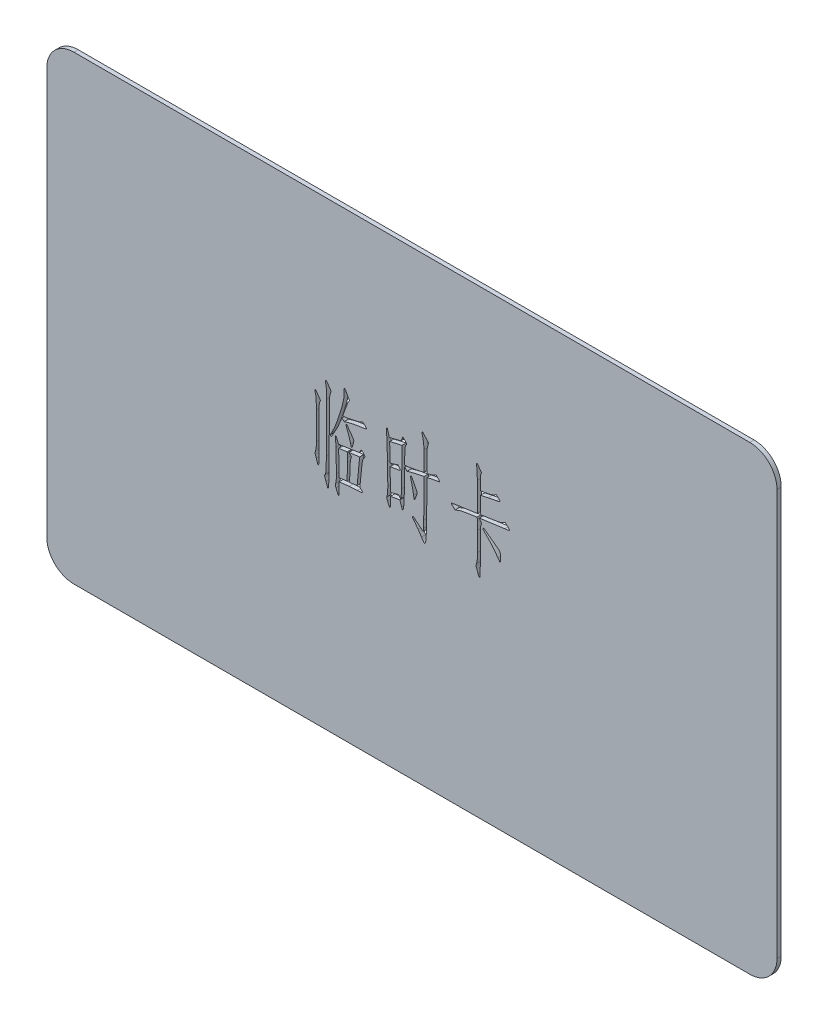
from build123d import *

# Parameters (mm, degrees)
SKETCH_1_W          = 85.6
SKETCH_1_H          = 54
EXTRUDE_1_DEPTH     = 0.5
CUT_EXTRUDE_1_DEPTH = 0.5
FILLET_1_R          = 3.18
FILLET_2_R          = 3.18


with BuildPart() as part:
    # 草图1 → 凸台-拉伸1 (new body)
    with BuildSketch(Plane.XY):
        with Locations((42.8, 27)):
            Rectangle(SKETCH_1_W, SKETCH_1_H)
    extrude(amount=EXTRUDE_1_DEPTH)

    # 草图2 → 切除-拉伸1 (cut)
    with BuildSketch(Plane.XY.offset(0.5)):
        with BuildLine():
            Line((31.503132567, 33.936108237), (31.963392528, 33.279811625))
            add(Edge.make_bspline(
                [(31.963392528, 33.279811625), (31.981078328, 33.252350472), (32.011774506, 33.204687803), (32.055946172, 33.146976419), (32.074726072, 33.107934182), (32.092294821, 33.086168682), (32.084178829, 33.06695685), (32.071883807, 33.043464326), (32.052003741, 33.00662995), (32.013038542, 32.942056313), (31.970597751, 32.840645055), (31.951912225, 32.723613117), (31.94453903, 32.615534282), (31.935113376, 32.516197794), (31.927976847, 32.399509095), (31.910476462, 32.228395715), (31.898688557, 32.017335525), (31.90328572, 31.85073494), (31.905433866, 31.772886417)],
                knots=[0, 0, 0, 0, 9.834e-05, 0.000170683, 0.000214244, 0.000233303, 0.000245713, 0.000272395, 0.000315114, 0.000370088, 0.000499249, 0.000641351, 0.000723459, 0.000824395, 0.000940625, 0.001074124, 0.001340401, 0.001573965, 0.001573965, 0.001573965, 0.001573965], degree=3))
            Line((31.905433866, 31.772886417), (31.939527197, 27.422577447))
            Line((31.939527197, 27.422577447), (31.917366532, 26.916291489))
            add(Edge.make_bspline(
                [(31.917366532, 26.916291489), (31.914325094, 26.859942278), (31.908848705, 26.758480344), (31.896859864, 26.625365958), (31.8792326, 26.524721034), (31.86451619, 26.46386102), (31.836727153, 26.419797843), (31.79488277, 26.438700918), (31.770649788, 26.489700962), (31.753841724, 26.533217007), (31.743490547, 26.560016185)],
                knots=[0, 0, 0, 0, 0.000169072, 0.000304429, 0.000403079, 0.000469386, 0.000504363, 0.000531316, 0.000585222, 0.000671641, 0.000671641, 0.000671641, 0.000671641], degree=3))
            Line((31.743490547, 26.560016185), (31.595184559, 26.986182816))
            Line((31.595184559, 26.986182816), (31.491199901, 27.30836479))
            add(Edge.make_bspline(
                [(31.491199901, 27.30836479), (31.482392373, 27.328702458), (31.466657222, 27.365036863), (31.449792822, 27.413590118), (31.440274613, 27.448227468), (31.436003442, 27.484364348), (31.4610294, 27.536229863), (31.487251409, 27.621857061), (31.524376906, 27.73687249), (31.548415746, 27.873976767), (31.570952938, 28.01802919), (31.591655278, 28.144491099), (31.605284742, 28.259926994), (31.613990233, 28.374192809), (31.615846507, 28.516403958), (31.616815679, 28.62039338), (31.617345224, 28.677212009)],
                knots=[0, 0, 0, 0, 6.6482e-05, 0.000118774, 0.000153916, 0.000174443, 0.000226205, 0.000320008, 0.000446222, 0.000586968, 0.000737182, 0.000883764, 0.000971301, 0.001085831, 0.00122736, 0.001397835, 0.001397835, 0.001397835, 0.001397835], degree=3))
            Line((31.617345224, 28.677212009), (31.605412558, 31.887099075))
            add(Edge.make_bspline(
                [(31.605412558, 31.887099075), (31.603670688, 31.999037051), (31.600460981, 32.205302862), (31.596584961, 32.487759312), (31.588389678, 32.716684957), (31.584455721, 32.8980351), (31.577099005, 33.042929643), (31.569457773, 33.16300598), (31.557717059, 33.262517759), (31.543385343, 33.34857591), (31.521558457, 33.433869833), (31.49706767, 33.533741522), (31.462131186, 33.653452639), (31.435636183, 33.739542871), (31.421308573, 33.786097583)],
                knots=[0, 0, 0, 0, 0.000335858, 0.000618879, 0.000847406, 0.001023061, 0.00116301, 0.001282641, 0.001383922, 0.001463513, 0.001544139, 0.001647914, 0.001772015, 0.00191815, 0.00191815, 0.00191815, 0.00191815], degree=3))
            Line((31.421308573, 33.786097583), (31.503132567, 33.936108237))
        make_face()
        with BuildLine():
            Line((32.745834463, 35.500992107), (33.354400412, 34.636726179))
            add(Edge.make_bspline(
                [(33.354400412, 34.636726179), (33.320672072, 34.561332709), (33.257467607, 34.420050811), (33.194806462, 34.203212096), (33.163776432, 33.985802492), (33.146503569, 33.763091258), (33.139026653, 33.540676962), (33.137114222, 33.395163504), (33.136203097, 33.325837621)],
                knots=[0, 0, 0, 0, 0.00024757, 0.000463929, 0.000674405, 0.000905297, 0.001133882, 0.001341879, 0.001341879, 0.001341879, 0.001341879], degree=3))
            Line((33.136203097, 33.325837621), (33.090177101, 26.34181887))
            add(Edge.make_bspline(
                [(33.090177101, 26.34181887), (33.088269852, 26.317395295), (33.083308271, 26.253859017), (33.081740441, 26.136108334), (33.076801935, 25.974212693), (33.07988348, 25.701374999), (33.071800899, 25.33510591), (33.048246638, 25.005344707), (33.028972086, 24.801144628), (33.016908771, 24.725631704), (33.000213651, 24.675059461), (32.989233396, 24.63887802), (32.959259049, 24.627032513), (32.935913585, 24.655047628), (32.916444475, 24.695699297), (32.902451528, 24.731691931), (32.894140451, 24.753069669)],
                knots=[0, 0, 0, 0, 7.3479e-05, 0.00019115, 0.000353129, 0.000559394, 0.001009542, 0.001452116, 0.001549819, 0.001626054, 0.001679445, 0.001712235, 0.001733798, 0.001760426, 0.001806954, 0.001875013, 0.001875013, 0.001875013, 0.001875013], degree=3))
            Line((32.894140451, 24.753069669), (32.733901797, 25.201396965))
            Line((32.733901797, 25.201396965), (32.595823809, 25.615630931))
            add(Edge.make_bspline(
                [(32.595823809, 25.615630931), (32.585154766, 25.639937077), (32.569246104, 25.676180095), (32.549963702, 25.723224535), (32.5638671, 25.751843619), (32.581424107, 25.779476348), (32.60422155, 25.821027168), (32.638119871, 25.870898794), (32.673451554, 25.935429917), (32.696956735, 26.017358663), (32.714063252, 26.11333982), (32.723227674, 26.22633739), (32.728805975, 26.361159178), (32.73829394, 26.521330643), (32.746024559, 26.709477251), (32.759646318, 26.991823607), (32.777731898, 27.347940166), (32.779215815, 27.632225632), (32.779927793, 27.768624751)],
                knots=[0, 0, 0, 0, 8.17e-05, 0.000121823, 0.000140183, 0.000173804, 0.000221168, 0.000281701, 0.000354903, 0.000440629, 0.000535923, 0.000647197, 0.000780336, 0.000940801, 0.001128508, 0.001345242, 0.001788852, 0.002198004, 0.002198004, 0.002198004, 0.002198004], degree=3))
            Line((32.779927793, 27.768624751), (32.814021124, 33.590060933))
            add(Edge.make_bspline(
                [(32.814021124, 33.590060933), (32.813649768, 33.702587882), (32.812871164, 33.938517304), (32.799198515, 34.235005466), (32.790131266, 34.472680082), (32.777053401, 34.632791797), (32.766030183, 34.771594961), (32.747579479, 34.929914533), (32.717363543, 35.117779981), (32.682045973, 35.264250953), (32.66401047, 35.339048787)],
                knots=[0, 0, 0, 0, 0.000337541, 0.000707705, 0.000890303, 0.001050986, 0.001189578, 0.001307988, 0.001529103, 0.001759857, 0.001759857, 0.001759857, 0.001759857], degree=3))
            Line((32.66401047, 35.339048787), (32.745834463, 35.500992107))
        make_face()
        with BuildLine():
            Line((33.228255089, 30.172204551), (33.366333078, 30.426199863))
            add(Edge.make_bspline(
                [(33.366333078, 30.426199863), (33.418069659, 30.523629017), (33.518437471, 30.7126394), (33.65458119, 30.992474107), (33.775243936, 31.258594148), (33.880324394, 31.523573771), (33.986606708, 31.804110585), (34.098028155, 32.122578456), (34.224829131, 32.486208303), (34.35543785, 32.883255605), (34.485020634, 33.280547275), (34.594351328, 33.651820528), (34.682614729, 33.979405597), (34.745500345, 34.265979822), (34.791790456, 34.510698941), (34.824780836, 34.714388576), (34.851549905, 34.876495379), (34.861068284, 35.002571057), (34.866613625, 35.100929114), (34.869080285, 35.181112289), (34.873991702, 35.247516292), (34.873483279, 35.287334555), (34.873258286, 35.304955456)],
                knots=[0, 0, 0, 0, 0.000330916, 0.00064197, 0.000933443, 0.001207258, 0.001496956, 0.001833394, 0.002219387, 0.002652255, 0.003087305, 0.003472971, 0.003813264, 0.004104847, 0.004352921, 0.004560303, 0.004723995, 0.004845458, 0.004939354, 0.005019546, 0.005086115, 0.00513896, 0.00513896, 0.00513896, 0.00513896], degree=3))
            Line((34.873258286, 35.304955456), (34.863030287, 35.673163426))
            Line((34.863030287, 35.673163426), (34.955082279, 35.731122088))
            Line((34.955082279, 35.731122088), (35.483528902, 34.774804167))
            add(Edge.make_bspline(
                [(35.483528902, 34.774804167), (35.458650142, 34.745065837), (35.410922237, 34.688015232), (35.354217851, 34.606932921), (35.31068183, 34.51697812), (35.265883924, 34.40556943), (35.206676499, 34.249098129), (35.163430548, 34.12937309), (35.139186264, 34.06225356)],
                knots=[0, 0, 0, 0, 0.000116343, 0.000223194, 0.000295617, 0.0004156, 0.000583395, 0.000797485, 0.000797485, 0.000797485, 0.000797485], degree=3))
            Line((35.139186264, 34.06225356), (34.689154301, 32.819551664))
            add(Edge.make_bspline(
                [(34.689154301, 32.819551664), (34.722129662, 32.820982648), (34.792733145, 32.824046526), (34.904694142, 32.834912963), (35.030468172, 32.849848403), (35.168623565, 32.873676914), (35.321471003, 32.895851437), (35.486031964, 32.927510806), (35.664422418, 32.963477215), (35.85014408, 33.003142971), (36.033054394, 33.043179881), (36.200822189, 33.080063428), (36.348462261, 33.114619506), (36.47528983, 33.144812588), (36.58170967, 33.171646695), (36.666932987, 33.196901792), (36.733458451, 33.213206634), (36.816120956, 33.246247555), (36.921870652, 33.297811055), (37.005867502, 33.354886821), (37.048412771, 33.383796283)],
                knots=[0, 0, 0, 0, 9.9003e-05, 0.000211975, 0.000337358, 0.000478886, 0.000632467, 0.000800642, 0.000981506, 0.00117843, 0.001370354, 0.001543233, 0.001693747, 0.001825227, 0.001934379, 0.002022891, 0.002091966, 0.002139453, 0.002289638, 0.002443785, 0.002443785, 0.002443785, 0.002443785], degree=3))
            Line((37.048412771, 33.383796283), (37.428553406, 33.037748979))
            add(Edge.make_bspline(
                [(37.428553406, 33.037748979), (37.441140452, 33.020730815), (37.463294861, 32.990777213), (37.482094266, 32.949255413), (37.477741313, 32.91704327), (37.456388525, 32.897733325), (37.424337765, 32.880236014), (37.397523302, 32.870835092), (37.38252741, 32.86557766)],
                knots=[0, 0, 0, 0, 6.3828e-05, 0.000112344, 0.000131403, 0.000156744, 0.00019417, 0.000241656, 0.000241656, 0.000241656, 0.000241656], degree=3))
            add(Edge.make_bspline(
                [(37.38252741, 32.86557766), (37.359937537, 32.857699745), (37.308800753, 32.839866478), (37.218809872, 32.822493465), (37.108863484, 32.808181077), (37.003087268, 32.796619088), (36.903833393, 32.789440929), (36.814361518, 32.77589199), (36.711174825, 32.763542655), (36.595484994, 32.743695159), (36.466425216, 32.721992806), (36.324425794, 32.696062105), (36.169843919, 32.66721652), (35.951174456, 32.625175218), (35.683045141, 32.567334613), (35.379096252, 32.493137388), (35.104227291, 32.413849681), (34.932683034, 32.353771291), (34.851097621, 32.325198371)],
                knots=[0, 0, 0, 0, 7.1697e-05, 0.000162302, 0.000274162, 0.000404433, 0.000481445, 0.000572577, 0.000675762, 0.000793186, 0.000924623, 0.001068402, 0.00122621, 0.001396378, 0.001736411, 0.002048975, 0.002334881, 0.002594176, 0.002594176, 0.002594176, 0.002594176], degree=3))
            Line((34.851097621, 32.325198371), (34.609034974, 32.577489017))
            add(Edge.make_bspline(
                [(34.609034974, 32.577489017), (34.565272961, 32.471235817), (34.483092538, 32.271703572), (34.3680839, 31.992080189), (34.26540559, 31.753012561), (34.17390812, 31.545064008), (34.081650994, 31.351045637), (33.983796347, 31.15187403), (33.87002096, 30.93993801), (33.76821846, 30.75763833), (33.686225019, 30.61282825), (33.628795136, 30.515201262), (33.580332095, 30.427944358), (33.535962392, 30.354186014), (33.499396447, 30.291491459), (33.470342442, 30.240416388), (33.443317483, 30.203450671), (33.429869123, 30.181364329), (33.42429174, 30.172204551)],
                knots=[0, 0, 0, 0, 0.000344739, 0.000647383, 0.00090703, 0.001125288, 0.001328887, 0.001551494, 0.00179095, 0.002050401, 0.002177898, 0.002290173, 0.002390184, 0.002477305, 0.002548351, 0.00260799, 0.00265338, 0.002685544, 0.002685544, 0.002685544, 0.002685544], degree=3))
            Line((33.42429174, 30.172204551), (33.332239747, 30.046059228))
            Line((33.332239747, 30.046059228), (33.228255089, 30.172204551))
        make_face()
        with BuildLine():
            Line((34.274920336, 25.927584905), (34.274920336, 24.995132316))
            add(Edge.make_bspline(
                [(34.274920336, 24.995132316), (34.273660543, 24.917316917), (34.271355245, 24.774922191), (34.257798346, 24.619932698), (34.238969178, 24.537084481), (34.231039751, 24.512359982), (34.213018906, 24.498775214), (34.193018932, 24.510540134), (34.174179782, 24.530884451), (34.152518671, 24.56635613), (34.127795546, 24.614712324), (34.111603236, 24.652362571), (34.102749017, 24.672950342)],
                knots=[0, 0, 0, 0, 0.000233639, 0.000427537, 0.000464335, 0.000488742, 0.000504824, 0.000523184, 0.000549702, 0.000590365, 0.000646022, 0.000713178, 0.000713178, 0.000713178, 0.000713178], degree=3))
            Line((34.102749017, 24.672950342), (33.906712366, 25.121277638))
            add(Edge.make_bspline(
                [(33.906712366, 25.121277638), (33.893665389, 25.152523666), (33.870499006, 25.208004522), (33.839782549, 25.280985109), (33.823924508, 25.334655272), (33.817783089, 25.374308445), (33.82553839, 25.408747259), (33.838590121, 25.449482287), (33.852397803, 25.503576459), (33.87492718, 25.568355719), (33.894974817, 25.648034878), (33.913925451, 25.742307561), (33.926546108, 25.852366879), (33.937034304, 25.976862926), (33.942182035, 26.115680264), (33.951069695, 26.267852238), (33.950627794, 26.432747585), (33.952018695, 26.546951695), (33.952738362, 26.606042181)],
                knots=[0, 0, 0, 0, 0.000101624, 0.000180446, 0.000237111, 0.000269679, 0.000299106, 0.000341723, 0.000398389, 0.000466319, 0.000547358, 0.000644643, 0.000754591, 0.000879451, 0.0010194, 0.001171269, 0.00133663, 0.001513924, 0.001513924, 0.001513924, 0.001513924], degree=3))
            Line((33.952738362, 26.606042181), (33.906712366, 29.229523963))
            Line((33.906712366, 29.229523963), (33.86068637, 29.954007236))
            Line((33.86068637, 29.954007236), (33.814660374, 30.334147871))
            Line((33.814660374, 30.334147871), (33.918645032, 30.402334532))
            Line((33.918645032, 30.402334532), (34.194801009, 29.711944589))
            Line((34.194801009, 29.711944589), (36.634178806, 30.080152559))
            Line((36.634178806, 30.080152559), (36.81828279, 30.402334532))
            add(Edge.make_bspline(
                [(36.81828279, 30.402334532), (36.825752315, 30.414961605), (36.838930453, 30.437238968), (36.872173215, 30.460047182), (36.911735946, 30.451121317), (36.932649467, 30.435178803), (36.944428113, 30.426199863)],
                knots=[0, 0, 0, 0, 4.3992e-05, 7.7614e-05, 0.000112088, 0.000156541, 0.000156541, 0.000156541, 0.000156541], degree=3))
            Line((36.944428113, 30.426199863), (37.22058409, 30.126178555))
            add(Edge.make_bspline(
                [(37.22058409, 30.126178555), (37.242499546, 30.100687071), (37.27810463, 30.05927217), (37.301437443, 29.992987504), (37.285687916, 29.946228108), (37.263251712, 29.902953688), (37.226295076, 29.848569427), (37.159772774, 29.759058178), (37.074453383, 29.62139179), (37.014668469, 29.419281887), (36.971784856, 29.197865096), (36.95367131, 29.043878681), (36.944428113, 28.965300651)],
                knots=[0, 0, 0, 0, 0.000101266, 0.000164523, 0.000196369, 0.000245922, 0.000311168, 0.00039301, 0.000580995, 0.000792848, 0.001020515, 0.001257752, 0.001257752, 0.001257752, 0.001257752], degree=3))
            Line((36.944428113, 28.965300651), (36.704070133, 26.594109516))
            Line((36.704070133, 26.594109516), (36.944428113, 26.34181887))
            add(Edge.make_bspline(
                [(36.944428113, 26.34181887), (36.960925741, 26.322045365), (36.989024421, 26.288367226), (36.999887541, 26.228981663), (36.985190074, 26.183163726), (36.958230065, 26.15736961), (36.927657323, 26.149326087), (36.895534487, 26.145485179), (36.849779268, 26.137450403), (36.788739916, 26.1335588), (36.713205639, 26.128125766), (36.622766223, 26.123819957), (36.518351729, 26.115733336), (36.44384097, 26.113096878), (36.404048825, 26.111688889)],
                knots=[0, 0, 0, 0, 7.6121e-05, 0.000129648, 0.000172773, 0.000216234, 0.000234031, 0.000266821, 0.000313349, 0.000373231, 0.000450112, 0.000540604, 0.000644812, 0.000764248, 0.000764248, 0.000764248, 0.000764248], degree=3))
            Line((36.404048825, 26.111688889), (35.437502905, 26.053730227))
            Line((35.437502905, 26.053730227), (34.274920336, 25.927584905))
        make_face()
        with BuildLine():
            Line((34.264692336, 26.34181887), (35.207372925, 26.456031527))
            Line((35.207372925, 26.456031527), (35.253398921, 28.412988697))
            add(Edge.make_bspline(
                [(35.253398921, 28.412988697), (35.253398921, 28.494244468), (35.253398921, 28.6436869), (35.253398921, 28.793129332), (35.253398921, 28.861315993)],
                knots=[0, 0, 0, 0, 0.000243767, 0.000448327, 0.000448327, 0.000448327, 0.000448327], degree=3))
            Line((35.253398921, 28.861315993), (35.241466255, 29.10337864))
            add(Edge.make_bspline(
                [(35.241466255, 29.10337864), (35.239277084, 29.132337259), (35.235373342, 29.183976412), (35.23631281, 29.251785875), (35.230684675, 29.299354091), (35.23109081, 29.324411562), (35.231238256, 29.333508621)],
                knots=[0, 0, 0, 0, 8.7088e-05, 0.000155296, 0.000203149, 0.000230423, 0.000230423, 0.000230423, 0.000230423], degree=3))
            Line((35.231238256, 29.333508621), (35.21930559, 29.447721278))
            Line((35.21930559, 29.447721278), (34.21866634, 29.297710624))
            Line((34.21866634, 29.297710624), (34.264692336, 26.34181887))
        make_face(mode=Mode.SUBTRACT)
        with BuildLine():
            add(Edge.make_bspline(
                [(35.495461567, 26.490124858), (35.517631368, 26.491113179), (35.566580017, 26.493295291), (35.646155873, 26.500383723), (35.738103156, 26.51105425), (35.842641141, 26.523109316), (35.95984562, 26.53610593), (36.089230437, 26.553948987), (36.231438702, 26.572140847), (36.330201809, 26.586562261), (36.38188816, 26.594109516)],
                knots=[0, 0, 0, 0, 6.6569e-05, 0.000146978, 0.000239597, 0.000344264, 0.000462674, 0.000593345, 0.00073607, 0.000892769, 0.000892769, 0.000892769, 0.000892769], degree=3))
            Line((36.38188816, 26.594109516), (36.680204802, 29.655690594))
            Line((36.680204802, 29.655690594), (35.415342241, 29.481814608))
            Line((35.415342241, 29.481814608), (35.737524214, 29.183497967))
            add(Edge.make_bspline(
                [(35.737524214, 29.183497967), (35.718472725, 29.141598086), (35.678065616, 29.052730855), (35.629086252, 28.930308048), (35.59747819, 28.800097704), (35.584148195, 28.655809977), (35.569655317, 28.468355924), (35.565785669, 28.328368748), (35.563648228, 28.251045378)],
                knots=[0, 0, 0, 0, 0.00013812, 0.000292945, 0.000394655, 0.000538858, 0.000726867, 0.000958858, 0.000958858, 0.000958858, 0.000958858], degree=3))
            Line((35.563648228, 28.251045378), (35.495461567, 26.490124858))
        make_face(mode=Mode.SUBTRACT)
        with BuildLine():
            Line((35.149414263, 32.197348382), (35.633539556, 31.576849767))
            Line((35.633539556, 31.576849767), (35.885830201, 31.184776466))
            add(Edge.make_bspline(
                [(35.885830201, 31.184776466), (35.899839946, 31.161680898), (35.925718905, 31.119018505), (35.956470755, 31.056689769), (35.979736685, 31.003743045), (35.994359556, 30.940738081), (35.99269031, 30.858884909), (35.976529545, 30.795257898), (35.967654194, 30.760314502)],
                knots=[0, 0, 0, 0, 8.0985e-05, 0.000149597, 0.000208476, 0.000253962, 0.000342604, 0.000450592, 0.000450592, 0.000450592, 0.000450592], degree=3))
            Line((35.967654194, 30.760314502), (35.81764354, 30.254028544))
            add(Edge.make_bspline(
                [(35.81764354, 30.254028544), (35.813836307, 30.23672471), (35.807287147, 30.206958845), (35.790017637, 30.170743283), (35.769529369, 30.146620803), (35.733075779, 30.138525749), (35.690199782, 30.176667178), (35.683527946, 30.217716653), (35.679565552, 30.242095878)],
                knots=[0, 0, 0, 0, 5.2927e-05, 9.1045e-05, 0.000119974, 0.000144381, 0.000194517, 0.000267837, 0.000267837, 0.000267837, 0.000267837], degree=3))
            Line((35.679565552, 30.242095878), (35.62160689, 30.472225859))
            add(Edge.make_bspline(
                [(35.62160689, 30.472225859), (35.586786087, 30.60092787), (35.515354405, 30.864948227), (35.386990688, 31.264032448), (35.238061549, 31.676619243), (35.126447863, 31.953360305), (35.069294936, 32.095068391)],
                knots=[0, 0, 0, 0, 0.000399943, 0.000820447, 0.001257221, 0.001715586, 0.001715586, 0.001715586, 0.001715586], degree=3))
            Line((35.069294936, 32.095068391), (35.149414263, 32.197348382))
        make_face()
        with BuildLine():
            Line((39.920775865, 34.188398883), (40.162838512, 33.371863618))
            Line((40.162838512, 33.371863618), (41.553846396, 33.728138921))
            Line((41.553846396, 33.728138921), (41.691924384, 34.096346891))
            add(Edge.make_bspline(
                [(41.691924384, 34.096346891), (41.697942424, 34.119711547), (41.707079559, 34.15518589), (41.743906869, 34.203904165), (41.803302659, 34.175456185), (41.83386281, 34.148249749), (41.853867704, 34.130440221)],
                knots=[0, 0, 0, 0, 7.4422e-05, 0.000112994, 0.00015725, 0.000241126, 0.000241126, 0.000241126, 0.000241126], degree=3))
            Line((41.853867704, 34.130440221), (42.130023681, 33.820190914))
            add(Edge.make_bspline(
                [(42.130023681, 33.820190914), (42.148114142, 33.798323742), (42.177389077, 33.762937135), (42.201249103, 33.695969698), (42.162444543, 33.626640387), (42.105560241, 33.541137414), (42.038649302, 33.412247175), (42.003795661, 33.272984485), (41.984410326, 33.134787454), (41.975612036, 32.999785217), (41.968274132, 32.837816275), (41.968148194, 32.72069356), (41.968080361, 32.657608344)],
                knots=[0, 0, 0, 0, 8.5608e-05, 0.000138535, 0.000198996, 0.000309221, 0.000454068, 0.000628993, 0.000737478, 0.000872534, 0.001034621, 0.001223847, 0.001223847, 0.001223847, 0.001223847], degree=3))
            Line((41.968080361, 32.657608344), (41.957852362, 31.460932443))
            Line((41.957852362, 31.460932443), (42.234008339, 31.484797775))
            Line((42.234008339, 31.484797775), (42.728361631, 31.552984436))
            Line((42.728361631, 31.552984436), (43.384658243, 31.680834425))
            Line((43.384658243, 31.680834425), (44.223354173, 31.853005744))
            Line((44.223354173, 31.853005744), (44.223354173, 34.176466217))
            add(Edge.make_bspline(
                [(44.223354173, 34.176466217), (44.223115446, 34.211139347), (44.222606265, 34.285093473), (44.214667324, 34.402124923), (44.205053151, 34.532371684), (44.184180972, 34.717058282), (44.156999232, 34.939686692), (44.122035426, 35.154838486), (44.090155673, 35.323825128), (44.055349101, 35.465279203), (44.010329016, 35.625774633), (43.97688889, 35.739118615), (43.959130862, 35.799308749)],
                knots=[0, 0, 0, 0, 0.000103999, 0.000221818, 0.000351776, 0.000495787, 0.000779326, 0.001024544, 0.001149578, 0.001295115, 0.001461371, 0.001649634, 0.001649634, 0.001649634, 0.001649634], degree=3))
            Line((43.959130862, 35.799308749), (44.051182854, 35.891360741))
            Line((44.051182854, 35.891360741), (44.765438128, 35.120851472))
            add(Edge.make_bspline(
                [(44.765438128, 35.120851472), (44.742596976, 35.052307347), (44.699097142, 34.921768484), (44.647329772, 34.731264139), (44.610645572, 34.555981871), (44.583671321, 34.338022049), (44.572585089, 34.063517356), (44.570491002, 33.842915141), (44.569401478, 33.728138921)],
                knots=[0, 0, 0, 0, 0.000216714, 0.000412721, 0.000591914, 0.000753453, 0.001070979, 0.001415359, 0.001415359, 0.001415359, 0.001415359], degree=3))
            Line((44.569401478, 33.728138921), (44.557468812, 31.910964406))
            Line((44.557468812, 31.910964406), (44.959770112, 32.013244397))
            add(Edge.make_bspline(
                [(44.959770112, 32.013244397), (45.023299271, 32.030039118), (45.147284114, 32.062816047), (45.322141723, 32.134428405), (45.484635522, 32.217966698), (45.580580207, 32.289730311), (45.627999389, 32.325198371)],
                knots=[0, 0, 0, 0, 0.000196924, 0.000384321, 0.000565818, 0.000743177, 0.000743177, 0.000743177, 0.000743177], degree=3))
            Line((45.627999389, 32.325198371), (45.996207359, 31.945057736))
            add(Edge.make_bspline(
                [(45.996207359, 31.945057736), (46.00854117, 31.927465973), (46.030625716, 31.895966699), (46.047454555, 31.846924521), (46.031565737, 31.798011554), (46.001164352, 31.796105822), (45.984274693, 31.795047082)],
                knots=[0, 0, 0, 0, 6.4327e-05, 0.000115182, 0.000151902, 0.000197801, 0.000197801, 0.000197801, 0.000197801], degree=3))
            Line((45.984274693, 31.795047082), (45.834264039, 31.760953752))
            add(Edge.make_bspline(
                [(45.834264039, 31.760953752), (45.82748062, 31.758549422), (45.804290299, 31.750329793), (45.752934119, 31.742737593), (45.672128937, 31.727526609), (45.583614762, 31.717023901), (45.493116786, 31.70436697), (45.406158745, 31.68885089), (45.304330509, 31.667229166), (45.185471241, 31.646705295), (45.051390857, 31.615966282), (44.900365624, 31.585084036), (44.734289443, 31.546266684), (44.618294003, 31.52048023), (44.557468812, 31.50695844)],
                knots=[0, 0, 0, 0, 2.1563e-05, 7.3715e-05, 0.000154987, 0.000268536, 0.000340859, 0.00042914, 0.000533446, 0.000653137, 0.000790889, 0.000946023, 0.001115575, 0.001302506, 0.001302506, 0.001302506, 0.001302506], degree=3))
            Line((44.557468812, 31.50695844), (44.535308147, 26.54808352))
            add(Edge.make_bspline(
                [(44.535308147, 26.54808352), (44.534019371, 26.543560467), (44.529913091, 26.529149178), (44.530995384, 26.498482534), (44.525619502, 26.452162451), (44.52332732, 26.388967277), (44.519084485, 26.309480611), (44.518768056, 26.213370858), (44.51437183, 26.101474362), (44.510457749, 25.933817484), (44.504591648, 25.723437238), (44.49017462, 25.483683754), (44.474883456, 25.265671733), (44.450237164, 25.074283995), (44.427674505, 24.914887782), (44.393115079, 24.797696057), (44.361782256, 24.720701111), (44.313655159, 24.683977023), (44.275004351, 24.697415643), (44.243165727, 24.719289775), (44.203622272, 24.753848038), (44.159713325, 24.804079036), (44.111241791, 24.869996491), (44.05237341, 24.947530824), (43.990274255, 25.041500316), (43.94762437, 25.109258888), (43.925037531, 25.14514297)],
                knots=[0, 0, 0, 0, 1.4057e-05, 4.4788e-05, 9.094e-05, 0.000154105, 0.000234297, 0.000329774, 0.000442333, 0.000570229, 0.000832886, 0.00107363, 0.001290793, 0.001488277, 0.001652501, 0.001773328, 0.001852645, 0.001903814, 0.001930277, 0.001968585, 0.002020542, 0.002086937, 0.002168423, 0.002265932, 0.00237893, 0.002506142, 0.002506142, 0.002506142, 0.002506142], degree=3))
            Line((43.925037531, 25.14514297), (43.522736232, 25.753708919))
            Line((43.522736232, 25.753708919), (43.038610939, 26.398072865))
            Line((43.038610939, 26.398072865), (42.86643962, 26.640135512))
            Line((42.86643962, 26.640135512), (42.924398281, 26.7782135))
            Line((42.924398281, 26.7782135), (43.118730265, 26.628202846))
            Line((43.118730265, 26.628202846), (43.752866212, 26.099756224))
            add(Edge.make_bspline(
                [(43.752866212, 26.099756224), (43.802050768, 26.058323359), (43.887625674, 25.986235416), (43.999793075, 25.887057911), (44.070152198, 25.841888669), (44.123128972, 25.792842176), (44.155997515, 25.837687747), (44.155814711, 25.904760071), (44.169368504, 26.016160029), (44.167937642, 26.105452988), (44.167100178, 26.157714885)],
                knots=[0, 0, 0, 0, 0.000194698, 0.00033875, 0.000432507, 0.000476729, 0.000504479, 0.000570347, 0.000681477, 0.000838316, 0.000838316, 0.000838316, 0.000838316], degree=3))
            Line((44.167100178, 26.157714885), (44.189260843, 26.996410816))
            Line((44.189260843, 26.996410816), (44.223354173, 31.438771779))
            add(Edge.make_bspline(
                [(44.223354173, 31.438771779), (44.058362521, 31.41150994), (43.726122678, 31.356613412), (43.228795615, 31.252723714), (42.730418889, 31.126184724), (42.400177431, 31.027944032), (42.234008339, 30.978511817)],
                knots=[0, 0, 0, 0, 0.000501647, 0.001010155, 0.001523653, 0.002043714, 0.002043714, 0.002043714, 0.002043714], degree=3))
            Line((42.234008339, 30.978511817), (41.957852362, 31.254667794))
            Line((41.957852362, 31.254667794), (41.922054365, 28.769264001))
            add(Edge.make_bspline(
                [(41.922054365, 28.769264001), (41.918712581, 28.680050444), (41.911369318, 28.484011867), (41.900780629, 28.234619914), (41.896023519, 28.028226424), (41.887699355, 27.890834624), (41.88413692, 27.775902066), (41.878532097, 27.707243295), (41.876028369, 27.676572759)],
                knots=[0, 0, 0, 0, 0.000267828, 0.000588527, 0.000748848, 0.000887094, 0.001001421, 0.001093725, 0.001093725, 0.001093725, 0.001093725], degree=3))
            Line((41.876028369, 27.676572759), (41.853867704, 27.30836479))
            add(Edge.make_bspline(
                [(41.853867704, 27.30836479), (41.849659272, 27.274866307), (41.842032481, 27.214158202), (41.834824671, 27.132045956), (41.825684467, 27.069112685), (41.816892788, 27.004724089), (41.793532019, 26.921529676), (41.762961947, 26.847535241), (41.739308373, 26.79292727), (41.718158304, 26.780491926), (41.695495587, 26.78873292), (41.678951238, 26.814918206), (41.656130763, 26.851359082), (41.634700853, 26.905790897), (41.613983955, 26.975329554), (41.59821665, 27.02653206), (41.589644393, 27.054369477)],
                knots=[0, 0, 0, 0, 0.000101281, 0.000183547, 0.000247193, 0.000292036, 0.000378455, 0.000504761, 0.00053458, 0.000553639, 0.000571436, 0.000600466, 0.000644027, 0.00070133, 0.00077465, 0.000862005, 0.000862005, 0.000862005, 0.000862005], degree=3))
            Line((41.589644393, 27.054369477), (41.393607742, 27.652707427))
            Line((41.393607742, 27.652707427), (40.3009165, 27.468603443))
            Line((40.3009165, 27.468603443), (40.288983834, 26.698094174))
            add(Edge.make_bspline(
                [(40.288983834, 26.698094174), (40.287233118, 26.643435411), (40.284203695, 26.548854399), (40.274335242, 26.429207895), (40.269265723, 26.349127613), (40.25743703, 26.304697163), (40.23889728, 26.278850203), (40.224419361, 26.282512676), (40.219092507, 26.283860208)],
                knots=[0, 0, 0, 0, 0.00016379, 0.000283421, 0.000362297, 0.000400032, 0.00042655, 0.000441986, 0.000441986, 0.000441986, 0.000441986], degree=3))
            add(Edge.make_bspline(
                [(40.219092507, 26.283860208), (40.209570109, 26.285895774), (40.188392123, 26.29042291), (40.16271777, 26.31904178), (40.137185701, 26.358291844), (40.124124821, 26.391444551), (40.116812515, 26.410005531)],
                knots=[0, 0, 0, 0, 2.8575e-05, 6.3552e-05, 0.000110361, 0.000169902, 0.000169902, 0.000169902, 0.000169902], degree=3))
            Line((40.116812515, 26.410005531), (39.954869196, 26.812306831))
            add(Edge.make_bspline(
                [(39.954869196, 26.812306831), (39.937957979, 26.854204885), (39.907589725, 26.929443155), (39.872951992, 27.030906829), (39.853083853, 27.108699656), (39.85151581, 27.152609351), (39.850884538, 27.170286801)],
                knots=[0, 0, 0, 0, 0.000135486, 0.000243299, 0.00032188, 0.000374834, 0.000374834, 0.000374834, 0.000374834], degree=3))
            add(Edge.make_bspline(
                [(39.850884538, 27.170286801), (39.851929833, 27.17655749), (39.854811995, 27.193847476), (39.86445943, 27.226572257), (39.87712571, 27.274194265), (39.908263959, 27.359517538), (39.940096949, 27.492892966), (39.956701568, 27.675095503), (39.9658134, 27.87309653), (39.970066127, 28.040258213), (39.975603502, 28.163514759), (39.976352897, 28.235152207), (39.979000722, 28.285124063), (39.978806338, 28.31127562), (39.978734527, 28.320936705)],
                knots=[0, 0, 0, 0, 1.9059e-05, 5.255e-05, 0.000102191, 0.000166878, 0.000324815, 0.000511747, 0.00071486, 0.000919533, 0.001013352, 0.001084968, 0.001134433, 0.001163412, 0.001163412, 0.001163412, 0.001163412], degree=3))
            Line((39.978734527, 28.320936705), (39.94293653, 30.806340498))
            Line((39.94293653, 30.806340498), (39.874749869, 33.049681644))
            Line((39.874749869, 33.049681644), (39.804858541, 34.166238218))
            Line((39.804858541, 34.166238218), (39.920775865, 34.188398883))
        make_face()
        with BuildLine():
            add(Edge.make_bspline(
                [(40.254890504, 30.840433828), (40.341047754, 30.854698976), (40.506425302, 30.882080713), (40.738453518, 30.94756647), (40.946334378, 31.026168044), (41.069856182, 31.095236604), (41.129384431, 31.128522471)],
                knots=[0, 0, 0, 0, 0.000261793, 0.000502507, 0.000722197, 0.000926558, 0.000926558, 0.000926558, 0.000926558], degree=3))
            Line((41.129384431, 31.128522471), (41.405540408, 30.806340498))
            add(Edge.make_bspline(
                [(41.405540408, 30.806340498), (41.417769332, 30.788985053), (41.439617785, 30.757977451), (41.450810341, 30.704370237), (41.424718683, 30.655087641), (41.389856216, 30.648308427), (41.369742411, 30.644397178)],
                knots=[0, 0, 0, 0, 6.344e-05, 0.000113344, 0.000156062, 0.000214321, 0.000214321, 0.000214321, 0.000214321], degree=3))
            Line((41.369742411, 30.644397178), (40.242957838, 30.448360528))
            Line((40.242957838, 30.448360528), (40.3009165, 27.860676743))
            add(Edge.make_bspline(
                [(40.3009165, 27.860676743), (40.356608244, 27.873144847), (40.463543943, 27.897085297), (40.616782955, 27.931933146), (40.755102709, 27.968557198), (40.879389716, 28.001781923), (40.988771604, 28.035423967), (41.082621828, 28.070365262), (41.163285572, 28.101106112), (41.210250798, 28.125644522), (41.231664422, 28.13683272)],
                knots=[0, 0, 0, 0, 0.000171215, 0.000328756, 0.000471399, 0.000600426, 0.000714727, 0.00081449, 0.000900909, 0.000973332, 0.000973332, 0.000973332, 0.000973332], degree=3))
            Line((41.231664422, 28.13683272), (41.485659735, 27.802718082))
            add(Edge.make_bspline(
                [(41.485659735, 27.802718082), (41.494448101, 27.847561484), (41.510118423, 27.927520664), (41.527360066, 28.032997278), (41.543195074, 28.108056297), (41.548930342, 28.163476697), (41.552672611, 28.216952036), (41.5583577, 28.286774346), (41.562115825, 28.381823474), (41.571115904, 28.49422892), (41.579522765, 28.608951278), (41.584223519, 28.711293308), (41.587951796, 28.793109153), (41.589136711, 28.840857884), (41.589644393, 28.861315993)],
                knots=[0, 0, 0, 0, 0.000137075, 0.000244415, 0.00032065, 0.000366959, 0.000411411, 0.000481489, 0.000577087, 0.000696718, 0.00081975, 0.000922157, 0.001004052, 0.001065444, 0.001065444, 0.001065444, 0.001065444], degree=3))
            Line((41.589644393, 28.861315993), (41.645898388, 33.313904956))
            Line((41.645898388, 33.313904956), (40.196931842, 32.979790317))
            Line((40.196931842, 32.979790317), (40.254890504, 30.840433828))
        make_face(mode=Mode.SUBTRACT)
        with BuildLine():
            Line((42.624376973, 30.644397178), (42.728361631, 30.760314502))
            Line((42.728361631, 30.760314502), (42.832346289, 30.576210517))
            Line((42.832346289, 30.576210517), (43.164756261, 29.94207457))
            add(Edge.make_bspline(
                [(43.164756261, 29.94207457), (43.186253569, 29.899411119), (43.226389587, 29.819757375), (43.283810182, 29.709240147), (43.328940812, 29.612789582), (43.368630683, 29.533989416), (43.397787431, 29.470212047), (43.418554243, 29.422416662), (43.430997247, 29.390444009), (43.438280441, 29.363993234), (43.425153319, 29.332899985), (43.414785191, 29.282897063), (43.388154676, 29.212133358), (43.37068861, 29.156857046), (43.360792912, 29.125539305)],
                knots=[0, 0, 0, 0, 0.000143324, 0.000267589, 0.000373567, 0.000462765, 0.000532177, 0.000584106, 0.000618623, 0.000636007, 0.000664121, 0.000715403, 0.000790872, 0.000889522, 0.000889522, 0.000889522, 0.000889522], degree=3))
            Line((43.360792912, 29.125539305), (43.222714923, 28.74539867))
            add(Edge.make_bspline(
                [(43.222714923, 28.74539867), (43.211044117, 28.716609967), (43.190468978, 28.665856701), (43.153566985, 28.604299799), (43.125283228, 28.562358878), (43.093748214, 28.540078366), (43.063620237, 28.54950397), (43.048923893, 28.579758966), (43.039754376, 28.622507681), (43.039029263, 28.657198519), (43.038610939, 28.677212009)],
                knots=[0, 0, 0, 0, 9.3119e-05, 0.000164165, 0.000213952, 0.000246742, 0.000269928, 0.000298299, 0.000342126, 0.000401887, 0.000401887, 0.000401887, 0.000401887], degree=3))
            Line((43.038610939, 28.677212009), (43.004517608, 28.919274655))
            add(Edge.make_bspline(
                [(43.004517608, 28.919274655), (43.001265332, 28.947138138), (42.993680414, 29.012120997), (42.976272003, 29.123023221), (42.950205919, 29.261615277), (42.917723864, 29.418204004), (42.885272907, 29.573766644), (42.858860904, 29.708163746), (42.836514004, 29.810290271), (42.818320664, 29.891415109), (42.801714675, 29.97444322), (42.772749008, 30.078898917), (42.737550071, 30.218399546), (42.709764495, 30.322253723), (42.694268301, 30.380173867)],
                knots=[0, 0, 0, 0, 8.4153e-05, 0.000196259, 0.000336685, 0.000507186, 0.000676017, 0.00081342, 0.000918073, 0.000989628, 0.001062849, 0.001172001, 0.001314644, 0.001494509, 0.001494509, 0.001494509, 0.001494509], degree=3))
            Line((42.694268301, 30.380173867), (42.624376973, 30.644397178))
        make_face()
        with BuildLine():
            Line((50.489708318, 30.816568497), (50.479480319, 34.166238218))
            add(Edge.make_bspline(
                [(50.479480319, 34.166238218), (50.477794861, 34.196354601), (50.473756455, 34.268514361), (50.466190877, 34.393444702), (50.462587522, 34.552657068), (50.455334866, 34.734449123), (50.449473998, 34.918591828), (50.442529757, 35.082232968), (50.436576351, 35.215306117), (50.427238604, 35.324958752), (50.416090991, 35.427216357), (50.402651269, 35.53757796), (50.382913065, 35.662857976), (50.370253688, 35.752128024), (50.363562995, 35.799308749)],
                knots=[0, 0, 0, 0, 9.0492e-05, 0.000216821, 0.000375438, 0.000568186, 0.000762637, 0.000928131, 0.001059567, 0.001162201, 0.001258209, 0.001368157, 0.001495688, 0.001638647, 0.001638647, 0.001638647, 0.001638647], degree=3))
            Line((50.363562995, 35.799308749), (50.443682321, 35.903293407))
            Line((50.443682321, 35.903293407), (50.973833611, 35.200970798))
            add(Edge.make_bspline(
                [(50.973833611, 35.200970798), (50.953118906, 35.158163439), (50.91510082, 35.079598289), (50.871839723, 34.959448745), (50.847733804, 34.832484574), (50.833669478, 34.6847693), (50.825793337, 34.505550635), (50.824518503, 34.375352131), (50.823822956, 34.304316207)],
                knots=[0, 0, 0, 0, 0.000142633, 0.000261777, 0.000381795, 0.000529197, 0.000706687, 0.000919798, 0.000919798, 0.000919798, 0.000919798], degree=3))
            Line((50.823822956, 34.304316207), (50.823822956, 33.279811625))
            add(Edge.make_bspline(
                [(50.823822956, 33.279811625), (50.912489683, 33.296162723), (51.080830422, 33.327206564), (51.319487435, 33.373240958), (51.530934708, 33.415594241), (51.715533409, 33.455142945), (51.873257215, 33.489721832), (52.003442883, 33.523529033), (52.107861249, 33.548638094), (52.254514408, 33.598847373), (52.454226045, 33.683317005), (52.616000885, 33.781683168), (52.698956134, 33.832123579)],
                knots=[0, 0, 0, 0, 0.000270484, 0.000513535, 0.000729167, 0.000917399, 0.001079925, 0.001213467, 0.001320969, 0.001401828, 0.001678263, 0.001969202, 0.001969202, 0.001969202, 0.001969202], degree=3))
            Line((52.698956134, 33.832123579), (53.091029434, 33.475848276))
            add(Edge.make_bspline(
                [(53.091029434, 33.475848276), (53.101032015, 33.460937555), (53.119924228, 33.432775173), (53.132819312, 33.386543228), (53.128467369, 33.339511688), (53.091922523, 33.310920779), (53.039822516, 33.297483647), (52.964617715, 33.279984686), (52.855298834, 33.258963951), (52.770557673, 33.242858255), (52.722821465, 33.233785629)],
                knots=[0, 0, 0, 0, 5.35e-05, 0.000101048, 0.000142524, 0.000185985, 0.00022911, 0.000304367, 0.000417365, 0.000563131, 0.000563131, 0.000563131, 0.000563131], degree=3))
            Line((52.722821465, 33.233785629), (51.74434288, 33.037748979))
            Line((51.74434288, 33.037748979), (50.835755622, 32.841712328))
            Line((50.835755622, 32.841712328), (50.847688288, 30.886459825))
            add(Edge.make_bspline(
                [(50.847688288, 30.886459825), (50.929517829, 30.897784457), (51.088082048, 30.919728627), (51.319309786, 30.952395758), (51.536941938, 30.98305213), (51.742216158, 31.011603458), (51.9335969, 31.040782606), (52.111452301, 31.068046784), (52.275629906, 31.093862898), (52.426288347, 31.117237505), (52.563701988, 31.139982439), (52.687828942, 31.15954426), (52.798460535, 31.180467483), (52.895644289, 31.199106314), (52.979247775, 31.215892522), (53.049551665, 31.231836508), (53.107013103, 31.243828517), (53.241458432, 31.289184603), (53.463980223, 31.373040369), (53.665039743, 31.46902746), (53.769486711, 31.518891105)],
                knots=[0, 0, 0, 0, 0.000247828, 0.000480226, 0.00070057, 0.000907173, 0.001101968, 0.001281339, 0.001446973, 0.001600554, 0.001738716, 0.001864826, 0.001977502, 0.002076461, 0.002161711, 0.002233267, 0.002292808, 0.002337554, 0.002658579, 0.003005637, 0.003005637, 0.003005637, 0.003005637], degree=3))
            Line((53.769486711, 31.518891105), (54.195653342, 31.10465714))
            add(Edge.make_bspline(
                [(54.195653342, 31.10465714), (54.205105586, 31.090422476), (54.222586232, 31.064097389), (54.234158685, 31.017722831), (54.216316188, 30.96822085), (54.188353424, 30.945779999), (54.171788011, 30.932485821)],
                knots=[0, 0, 0, 0, 5.1168e-05, 9.4629e-05, 0.000137754, 0.000200434, 0.000200434, 0.000200434, 0.000200434], degree=3))
            Line((54.171788011, 30.932485821), (53.70130005, 30.874527159))
            Line((53.70130005, 30.874527159), (50.709610299, 30.460293194))
            Line((50.709610299, 30.460293194), (50.985766276, 30.023898563))
            add(Edge.make_bspline(
                [(50.985766276, 30.023898563), (50.954965178, 29.960063491), (50.895358666, 29.836529389), (50.854390459, 29.668777601), (50.840282754, 29.529668657), (50.829014075, 29.412705086), (50.824853376, 29.280123748), (50.824180038, 29.186906506), (50.823822956, 29.13747197)],
                knots=[0, 0, 0, 0, 0.000212202, 0.000410655, 0.000513628, 0.000631694, 0.000763053, 0.000911369, 0.000911369, 0.000911369, 0.000911369], degree=3))
            Line((50.823822956, 29.13747197), (50.823822956, 25.811667581))
            add(Edge.make_bspline(
                [(50.823822956, 25.811667581), (50.823106428, 25.745757716), (50.821753664, 25.621323854), (50.822085801, 25.44394203), (50.813790259, 25.287176309), (50.80546742, 25.106517687), (50.790967488, 24.900315026), (50.796431163, 24.70671032), (50.793231685, 24.571553561), (50.785754567, 24.501335101), (50.753908569, 24.451767135), (50.723583187, 24.453811195), (50.709610299, 24.454753027)],
                knots=[0, 0, 0, 0, 0.000197749, 0.000373338, 0.000532018, 0.000668562, 0.000916026, 0.00115127, 0.0012502, 0.001319737, 0.001365794, 0.00140515, 0.00140515, 0.00140515, 0.00140515], degree=3))
            add(Edge.make_bspline(
                [(50.709610299, 24.454753027), (50.699894251, 24.460417163), (50.671123465, 24.477189582), (50.646005311, 24.542706677), (50.599511179, 24.631757518), (50.574239198, 24.708572365), (50.559599645, 24.753069669)],
                knots=[0, 0, 0, 0, 3.3099e-05, 9.801e-05, 0.000199449, 0.000339117, 0.000339117, 0.000339117, 0.000339117], degree=3))
            Line((50.559599645, 24.753069669), (50.409588991, 25.1792363))
            Line((50.409588991, 25.1792363), (50.34140233, 25.351407619))
            add(Edge.make_bspline(
                [(50.34140233, 25.351407619), (50.338010084, 25.367860725), (50.330907826, 25.402308168), (50.31834783, 25.46192971), (50.331774212, 25.543805013), (50.351627183, 25.603566837), (50.363562995, 25.639496262)],
                knots=[0, 0, 0, 0, 5.0482e-05, 0.000105694, 0.000181182, 0.000294986, 0.000294986, 0.000294986, 0.000294986], degree=3))
            add(Edge.make_bspline(
                [(50.363562995, 25.639496262), (50.383757264, 25.699887452), (50.42085824, 25.810838342), (50.454215821, 25.981540213), (50.467441201, 26.163244539), (50.478848388, 26.37238791), (50.487384894, 26.605981529), (50.488933977, 26.767411062), (50.489708318, 26.848104828)],
                knots=[0, 0, 0, 0, 0.000190877, 0.00035068, 0.000520138, 0.000736959, 0.000979172, 0.001221258, 0.001221258, 0.001221258, 0.001221258], degree=3))
            Line((50.489708318, 26.848104828), (50.489708318, 29.113606639))
            add(Edge.make_bspline(
                [(50.489708318, 29.113606639), (50.489708338, 29.165314857), (50.489708376, 29.261912628), (50.48970813, 29.397149501), (50.489708876, 29.513066838), (50.489706746, 29.609664569), (50.489712394, 29.686942889), (50.489698591, 29.744901295), (50.489726994, 29.78354093), (50.489670648, 29.812519215), (50.490011131, 29.844356116), (50.487465415, 29.891488958), (50.486181177, 29.956845595), (50.484633455, 30.033559459), (50.482947347, 30.109700629), (50.481899964, 30.171657601), (50.479242271, 30.21366776), (50.479418452, 30.234707645), (50.479480319, 30.242095878)],
                knots=[0, 0, 0, 0, 0.000155125, 0.000289793, 0.000405711, 0.000502877, 0.000579587, 0.000637545, 0.000676753, 0.000695504, 0.000724483, 0.000772244, 0.000837044, 0.00092059, 0.001002432, 0.001065528, 0.001106475, 0.001128636, 0.001128636, 0.001128636, 0.001128636], degree=3))
            Line((50.479480319, 30.242095878), (50.443682321, 30.426199863))
            add(Edge.make_bspline(
                [(50.443682321, 30.426199863), (50.304475068, 30.405131406), (50.041950721, 30.365399403), (49.672359655, 30.31014387), (49.351550304, 30.25807586), (49.079065596, 30.214975437), (48.855947789, 30.175173053), (48.68172332, 30.143881862), (48.55667901, 30.116979778), (48.450931129, 30.089536574), (48.341660572, 30.05024582), (48.204254171, 29.996820169), (48.042304743, 29.934578545), (47.9274877, 29.887222357), (47.866226536, 29.861955243)],
                knots=[0, 0, 0, 0, 0.000422379, 0.000796545, 0.001121077, 0.001397401, 0.001624128, 0.001800995, 0.001928389, 0.00200778, 0.002128535, 0.00227638, 0.002450172, 0.002648969, 0.002648969, 0.002648969, 0.002648969], degree=3))
            Line((47.866226536, 29.861955243), (47.509951233, 30.196069882))
            add(Edge.make_bspline(
                [(47.509951233, 30.196069882), (47.493938405, 30.212084091), (47.462311473, 30.243713752), (47.447151609, 30.306968498), (47.461154922, 30.374438488), (47.501649431, 30.386219664), (47.521883898, 30.392106533)],
                knots=[0, 0, 0, 0, 6.6569e-05, 0.000131481, 0.000190261, 0.000248967, 0.000248967, 0.000248967, 0.000248967], degree=3))
            Line((47.521883898, 30.392106533), (47.948050529, 30.448360528))
            Line((47.948050529, 30.448360528), (50.489708318, 30.816568497))
        make_face()
        with BuildLine():
            Line((51.123844265, 29.53977327), (51.192030926, 29.723877255))
            Line((51.192030926, 29.723877255), (52.860899453, 28.493108024))
            add(Edge.make_bspline(
                [(52.860899453, 28.493108024), (52.896871803, 28.465530403), (52.960660788, 28.416627608), (53.04174707, 28.349553699), (53.094081183, 28.296681729), (53.128233269, 28.252826941), (53.138487443, 28.19914747), (53.155948134, 28.130320148), (53.166518959, 28.03210352), (53.177126231, 27.958342228), (53.183081427, 27.916930739)],
                knots=[0, 0, 0, 0, 0.000136053, 0.00024126, 0.000314799, 0.000360189, 0.000404444, 0.000476, 0.000574118, 0.000699721, 0.000699721, 0.000699721, 0.000699721], degree=3))
            Line((53.183081427, 27.916930739), (53.205242091, 27.434510112))
            add(Edge.make_bspline(
                [(53.205242091, 27.434510112), (53.206447067, 27.402682786), (53.208559718, 27.346880775), (53.203733831, 27.275330525), (53.189802054, 27.226357172), (53.160949536, 27.200181891), (53.128422048, 27.204403154), (53.098999546, 27.222291857), (53.070599456, 27.254214196), (53.054154628, 27.281338202), (53.045003438, 27.296432124)],
                knots=[0, 0, 0, 0, 9.5477e-05, 0.000167397, 0.000214883, 0.000245234, 0.000274263, 0.000305557, 0.000347762, 0.000400717, 0.000400717, 0.000400717, 0.000400717], degree=3))
            Line((53.045003438, 27.296432124), (52.883060118, 27.53849477))
            add(Edge.make_bspline(
                [(52.883060118, 27.53849477), (52.780528028, 27.678951015), (52.571554895, 27.965218285), (52.321481314, 28.281085127), (52.144253619, 28.501677808), (52.035719984, 28.621377563), (51.9170718, 28.752676253), (51.785563703, 28.893377949), (51.638217258, 29.041011745), (51.478669479, 29.199109152), (51.305866066, 29.366688314), (51.185880491, 29.480782878), (51.123844265, 29.53977327)],
                knots=[0, 0, 0, 0, 0.000521639, 0.001063165, 0.001208532, 0.001370341, 0.001547733, 0.001739483, 0.001948018, 0.002173427, 0.002413325, 0.002670142, 0.002670142, 0.002670142, 0.002670142], degree=3))
        make_face()
    extrude(amount=-CUT_EXTRUDE_1_DEPTH, mode=Mode.SUBTRACT)

    # 圆角1
    fillet_1_edges = [part.edges().sort_by_distance(p)[0] for p in [
        (0, 54, 0.25),
    ]]
    fillet(fillet_1_edges, radius=FILLET_1_R)

    # 圆角2
    fillet_2_edges = [part.edges().sort_by_distance(p)[0] for p in [
        (0, 0, 0.25),
        (85.6, 0, 0.25),
        (85.6, 54, 0.25),
    ]]
    fillet(fillet_2_edges, radius=FILLET_2_R)


solid = part.part
